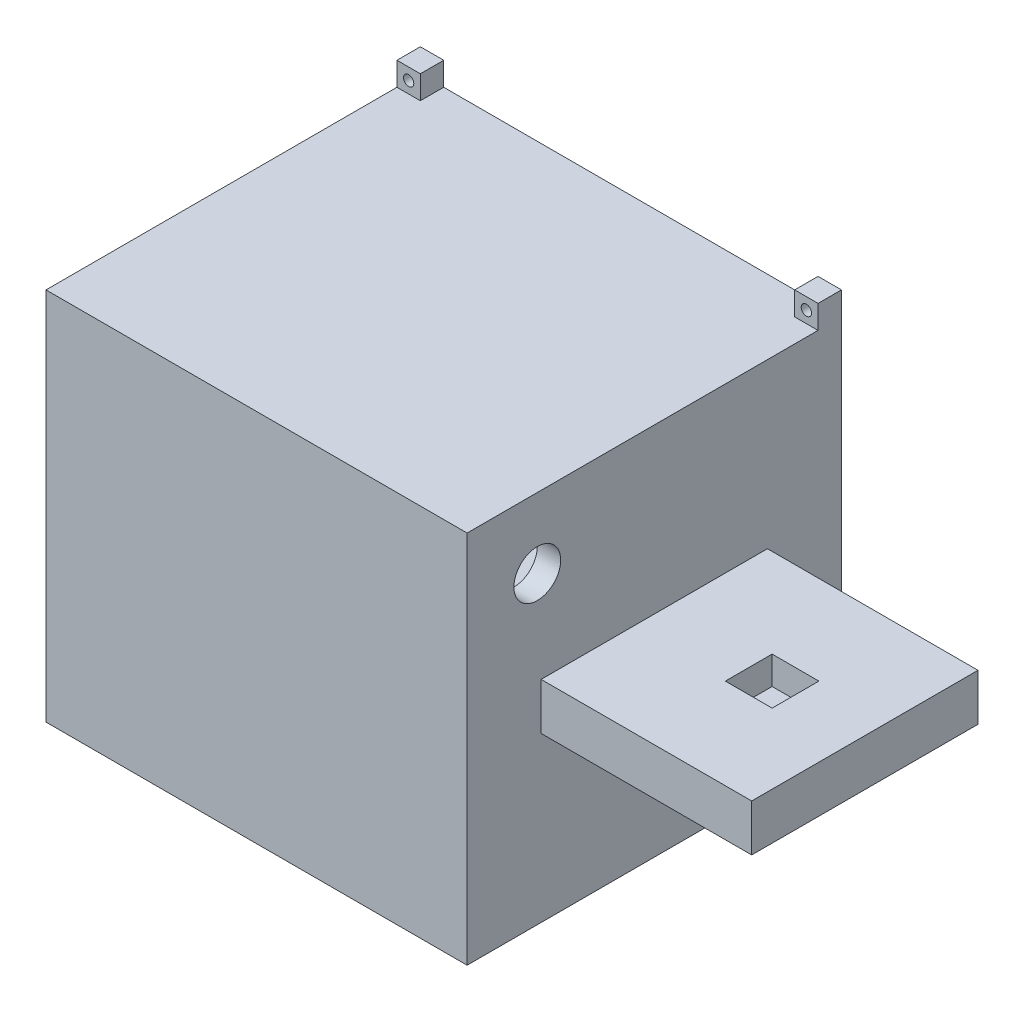
from build123d import *

# Parameters (mm, degrees)
SKETCH_1_W           = 135
SKETCH_1_H           = 80
EXTRUDE_1_DEPTH      = 80
SKETCH_6_W           = 45
SKETCH_6_H           = 80
CUT_EXTRUDE_1_DEPTH  = 35
SKETCH_5_W           = 45
SKETCH_5_H           = 80
CUT_EXTRUDE_2_DEPTH  = 35
SKETCH_7_W           = 80
SKETCH_7_H           = 70
CUT_EXTRUDE_3_DEPTH  = 75
SKETCH_8_W           = 87.8
SKETCH_8_H           = 77.8
SKETCH_8_W_2         = 82.2
SKETCH_8_H_2         = 72.2
CUT_EXTRUDE_4_DEPTH  = 10
SKETCH_9_R           = 5
CUT_EXTRUDE_5_DEPTH  = 32.4
SKETCH_10_W          = 21.5
SKETCH_10_H          = 15
CUT_EXTRUDE_6_DEPTH  = 10
SKETCH_12_W          = 15.816906699
SKETCH_12_H          = 10
CUT_EXTRUDE_7_DEPTH  = 45
CUT_EXTRUDE_8_DEPTH  = 3
SKETCH_15_W          = 10
SKETCH_15_H          = 10
CUT_EXTRUDE_9_DEPTH  = 6
SKETCH_17_R          = 1.095275866
CUT_EXTRUDE_11_DEPTH = 7
SKETCH_18_W          = 5
SKETCH_18_H          = 5
SKETCH_18_R          = 1.1
EXTRUDE_2_DEPTH      = 5


with BuildPart() as part:
    # 草圖1 → 填料-伸長1 (new body)
    with BuildSketch(Plane.XY):
        with Locations((-8.008902174, 5.58988764)):
            Rectangle(SKETCH_1_W, SKETCH_1_H)
    extrude(amount=EXTRUDE_1_DEPTH)

    # 草圖6 → 除料-伸長1 (cut)
    with BuildSketch(Plane(origin=(0, 45.58988764, 0), x_dir=(1, 0, 0), z_dir=(0, 1, 0))):
        with Locations((36.991097826, -40)):
            Rectangle(SKETCH_6_W, SKETCH_6_H)
    extrude(amount=-CUT_EXTRUDE_1_DEPTH, mode=Mode.SUBTRACT)

    # 草圖5 → 除料-伸長2 (cut)
    with BuildSketch(Plane.XZ.offset(34.41011236)):
        with Locations((36.991097826, 40)):
            Rectangle(SKETCH_5_W, SKETCH_5_H)
    extrude(amount=-CUT_EXTRUDE_2_DEPTH, mode=Mode.SUBTRACT)

    # 草圖7 → 除料-伸長3 (cut)
    with BuildSketch(Plane.XY):
        with Locations((-30.508902174, 5.58988764)):
            Rectangle(SKETCH_7_W, SKETCH_7_H)
    extrude(amount=CUT_EXTRUDE_3_DEPTH, mode=Mode.SUBTRACT)

    # 草圖8 → 除料-伸長4 (cut)
    with BuildSketch(Plane(origin=(0, 0, 0), x_dir=(-1, 0, 0), z_dir=(0, 0, -1))):
        with Locations((30.508902174, 5.58988764)):
            Rectangle(SKETCH_8_W, SKETCH_8_H)
        with Locations((30.508902174, 5.58988764)):
            Rectangle(SKETCH_8_W_2, SKETCH_8_H_2, mode=Mode.SUBTRACT)
    extrude(amount=-CUT_EXTRUDE_4_DEPTH, mode=Mode.SUBTRACT)

    # 草圖9 → 除料-伸長5 (cut)
    with BuildSketch(Plane(origin=(14.491097826, 0, 0), x_dir=(0, 0, -1), z_dir=(1, 0, 0))):
        with Locations((-65, 30.58988764)):
            Circle(SKETCH_9_R)
        with Locations((-20, -19.41011236)):
            Circle(SKETCH_9_R)
    extrude(amount=-CUT_EXTRUDE_5_DEPTH, mode=Mode.SUBTRACT)

    # 草圖10 → 除料-伸長6 (cut)
    with BuildSketch(Plane(origin=(0, -34.41011236, 0), x_dir=(-1, 0, 0), z_dir=(0, -1, 0))):
        with Locations((24.758902174, -22.5)):
            Rectangle(SKETCH_10_W, SKETCH_10_H)
    extrude(amount=-CUT_EXTRUDE_6_DEPTH, mode=Mode.SUBTRACT)

    # 草圖12 → 除料-伸長7 (cut)
    with BuildSketch(Plane(origin=(14.491097826, 0, 0), x_dir=(0, 0, -1), z_dir=(1, 0, 0))):
        with Locations((-72.09154665, 5.58988764)):
            Rectangle(SKETCH_12_W, SKETCH_12_H)
        with Locations((-7.90845335, 5.58988764)):
            Rectangle(SKETCH_12_W, SKETCH_12_H)
    extrude(amount=CUT_EXTRUDE_7_DEPTH, mode=Mode.SUBTRACT)

    # 草圖14 → 除料-伸長8 (cut)
    with BuildSketch(Plane(origin=(0, 0.58988764, 0), x_dir=(-1, 0, 0), z_dir=(0, -1, 0))):
        with BuildLine():
            Line((-38.009101008, -35.10282789), (-21.517914827, -38.5))
            ThreePointArc((-21.517914827, -38.5), (-20.017914827, -40), (-21.517914827, -41.5))
            Line((-21.517914827, -41.5), (-38.009101008, -44.89717211))
            ThreePointArc((-38.009101008, -44.89717211), (-39.017914827, -45), (-40.026728646, -44.89717211))
            Line((-40.026728646, -44.89717211), (-56.517914827, -41.5))
            ThreePointArc((-56.517914827, -41.5), (-58.017914827, -40), (-56.517914827, -38.5))
            Line((-56.517914827, -38.5), (-40.026728646, -35.10282789))
            ThreePointArc((-40.026728646, -35.10282789), (-39.017914827, -35), (-38.009101008, -35.10282789))
        make_face()
    extrude(amount=-CUT_EXTRUDE_8_DEPTH, mode=Mode.SUBTRACT)

    # 草圖15 → 除料-伸長9 (cut)
    with BuildSketch(Plane(origin=(0, 10.58988764, 0), x_dir=(1, 0, 0), z_dir=(0, 1, 0))):
        with Locations((39.491097826, -39.816906699)):
            Rectangle(SKETCH_15_W, SKETCH_15_H)
    extrude(amount=-CUT_EXTRUDE_9_DEPTH, mode=Mode.SUBTRACT)

    # 草圖17 → 除料-伸長11 (cut)
    with BuildSketch(Plane(origin=(0, 0.58988764, 0), x_dir=(-1, 0, 0), z_dir=(0, -1, 0))):
        with Locations((-39.017914827, -40)):
            Circle(SKETCH_17_R)
    extrude(amount=-CUT_EXTRUDE_11_DEPTH, mode=Mode.SUBTRACT)

    # 草圖18 → 填料-伸長2 (add)
    with BuildSketch(Plane.XY):
        with Locations((11.991097826, 48.08988764)):
            Rectangle(SKETCH_18_W, SKETCH_18_H)
        with Locations((11.991097826, 48.08988764)):
            Circle(SKETCH_18_R, mode=Mode.SUBTRACT)
        with Locations((-73.008902174, 48.08988764)):
            Rectangle(SKETCH_18_W, SKETCH_18_H)
        with Locations((-73.008902174, 48.08988764)):
            Circle(SKETCH_18_R, mode=Mode.SUBTRACT)
        with Locations((-73.008902174, -36.91011236)):
            Rectangle(SKETCH_18_W, SKETCH_18_H)
        with Locations((-73.008902174, -36.91011236)):
            Circle(SKETCH_18_R, mode=Mode.SUBTRACT)
        with Locations((11.991097826, -36.91011236)):
            Rectangle(SKETCH_18_W, SKETCH_18_H)
        with Locations((11.991097826, -36.91011236)):
            Circle(SKETCH_18_R, mode=Mode.SUBTRACT)
    extrude(amount=EXTRUDE_2_DEPTH)


solid = part.part
